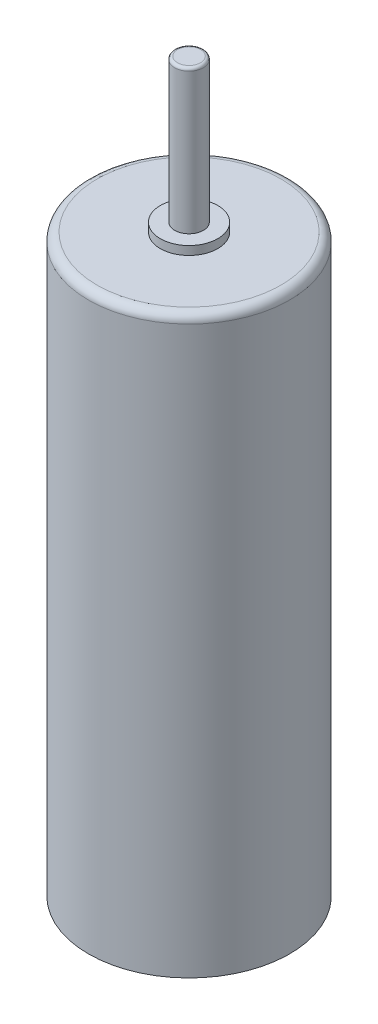
from build123d import *

# Parameters (mm, degrees)
SKETCH1_R           = 3.5
BOSS_EXTRUDE1_DEPTH = 20
FILLET1_R           = 0.3
SKETCH2_R           = 1
BOSS_EXTRUDE2_DEPTH = 0.3
SKETCH3_R           = 0.5
BOSS_EXTRUDE3_DEPTH = 5
FILLET2_R           = 0.1


with BuildPart() as part:
    # Sketch1 → Boss-Extrude1 (new body)
    with BuildSketch(Plane(origin=(0, 0, 0), x_dir=(1, 0, 0), z_dir=(0, 1, 0))):
        Circle(SKETCH1_R)
    extrude(amount=BOSS_EXTRUDE1_DEPTH)

    # Fillet1
    fillet1_edges = [part.edges().sort_by_distance(p)[0] for p in [
        (-3.5, 20, 0),
    ]]
    fillet(fillet1_edges, radius=FILLET1_R)

    # Sketch2 → Boss-Extrude2 (add)
    with BuildSketch(Plane(origin=(0, 20, 0), x_dir=(1, 0, 0), z_dir=(0, 1, 0))):
        Circle(SKETCH2_R)
    extrude(amount=BOSS_EXTRUDE2_DEPTH)

    # Sketch3 → Boss-Extrude3 (add)
    with BuildSketch(Plane(origin=(0, 20.3, 0), x_dir=(1, 0, 0), z_dir=(0, 1, 0))):
        Circle(SKETCH3_R)
    extrude(amount=BOSS_EXTRUDE3_DEPTH)

    # Fillet2
    fillet2_edges = [part.edges().sort_by_distance(p)[0] for p in [
        (-0.5, 25.3, 0),
    ]]
    fillet(fillet2_edges, radius=FILLET2_R)


solid = part.part
